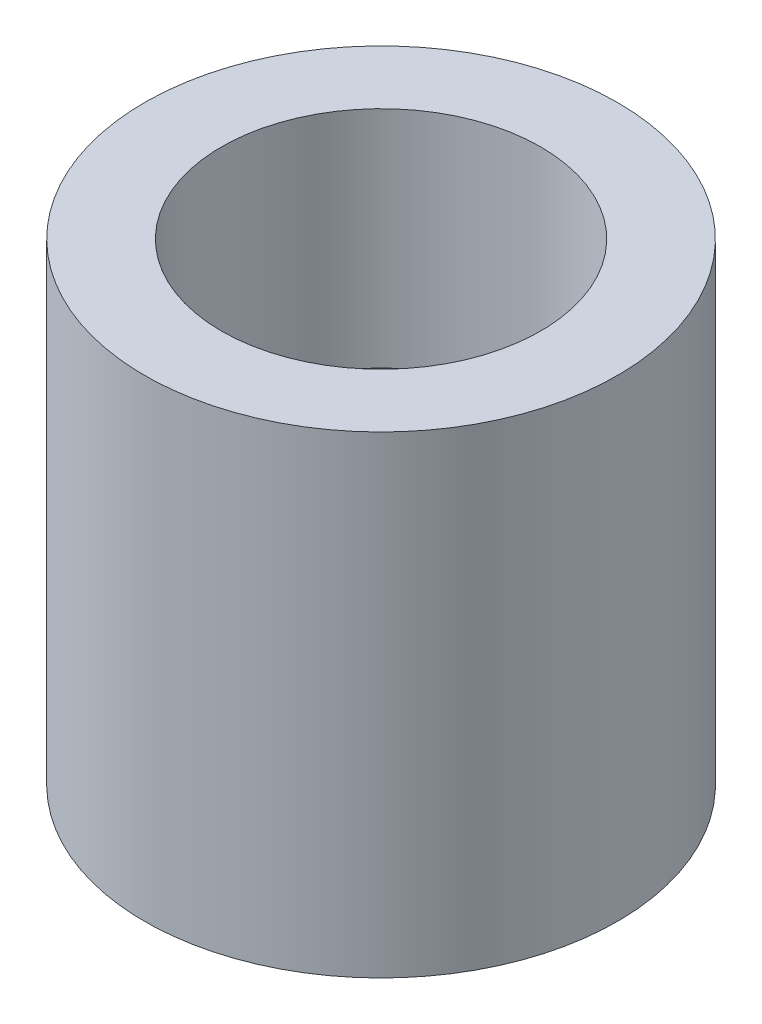
from build123d import *


with BuildPart() as part:
    # Эскиз1 → Повернуть1 (revolve)
    with BuildSketch(Plane.XY):
        Polygon((7.25, 0), (10, 0), (10, 20), (6.75, 20), (6.75, 10.5), (7.25, 10.5), align=None)
    revolve(axis=Axis((0, -6.710269619, 0), (0, 1, 0)))


solid = part.part
